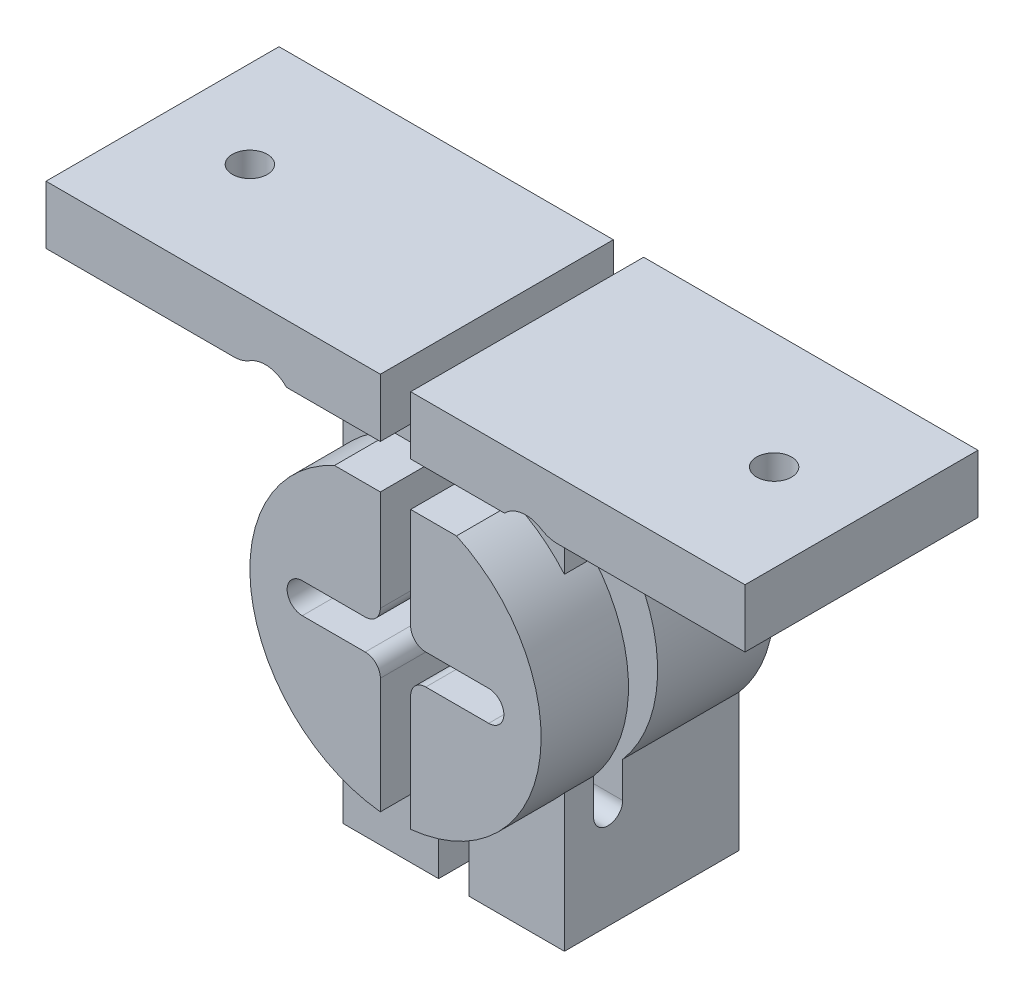
from build123d import *

# Parameters (mm, degrees)
SKETCH1_W           = 76.2
SKETCH1_H           = 50.8
BOSS_EXTRUDE1_DEPTH = 25.4
SKETCH2_W           = 76.2
SKETCH2_H           = 44.45
SKETCH2_R           = 15.875
CUT_EXTRUDE1_DEPTH  = 6.35
CUT_EXTRUDE2_DEPTH  = 12.7
CUT_EXTRUDE3_START  = -19.05
CUT_EXTRUDE3_DEPTH  = 19.05
CUT_EXTRUDE4_START  = -15.875
CUT_EXTRUDE4_DEPTH  = 31.75
CUT_EXTRUDE5_START  = -19.05
SKETCH7_R           = 3.175
CUT_EXTRUDE5_DEPTH  = 25.4
FILLET1_R           = 3.302
SKETCH8_R           = 1.905
CUT_EXTRUDE6_DEPTH  = 6.35
SKETCH9_W           = 3.302
SKETCH9_H           = 50.8
CUT_EXTRUDE7_DEPTH  = 12.7
SKETCH10_W          = 23.773678362
SKETCH10_H          = 4.7625
CUT_EXTRUDE8_DEPTH  = 6.35


with BuildPart() as part:
    # Sketch1 → Boss-Extrude1 (new body)
    with BuildSketch(Plane.XY):
        Rectangle(SKETCH1_W, SKETCH1_H)
    extrude(amount=BOSS_EXTRUDE1_DEPTH)

    # Sketch2 → Cut-Extrude1 (cut)
    with BuildSketch(Plane.XY.offset(25.4)):
        with Locations((0, -3.175)):
            Rectangle(SKETCH2_W, SKETCH2_H)
        with Locations((0, -0.127)):
            Circle(SKETCH2_R, mode=Mode.SUBTRACT)
    extrude(amount=-CUT_EXTRUDE1_DEPTH, mode=Mode.SUBTRACT)

    # Sketch3 → Cut-Extrude2 (cut)
    with BuildSketch(Plane.XY.offset(25.4)):
        with BuildLine():
            Line((10.16, -1.651), (3.302, -1.651))
            ThreePointArc((3.302, -1.651), (2.134566704, -2.134566704), (1.651, -3.302))
            Line((1.651, -3.302), (1.651, -25.4))
            Line((1.651, -25.4), (-1.651, -25.4))
            Line((-1.651, -25.4), (-1.651, -3.302))
            ThreePointArc((-1.651, -3.302), (-2.134566704, -2.134566704), (-3.302, -1.651))
            Line((-3.302, -1.651), (-10.16, -1.651))
            ThreePointArc((-10.16, -1.651), (-11.811, 0), (-10.16, 1.651))
            Line((-10.16, 1.651), (-3.302, 1.651))
            ThreePointArc((-3.302, 1.651), (-2.134566704, 2.134566704), (-1.651, 3.302))
            Line((-1.651, 3.302), (-1.651, 25.4))
            Line((-1.651, 25.4), (1.651, 25.4))
            Line((1.651, 25.4), (1.651, 3.302))
            ThreePointArc((1.651, 3.302), (2.134566704, 2.134566704), (3.302, 1.651))
            Line((3.302, 1.651), (10.16, 1.651))
            ThreePointArc((10.16, 1.651), (11.811, 0), (10.16, -1.651))
        make_face()
    extrude(amount=-CUT_EXTRUDE2_DEPTH, mode=Mode.SUBTRACT)

    # Sketch4 → Cut-Extrude3 (cut)
    with BuildSketch(Plane.XY.offset(19.05).offset(CUT_EXTRUDE3_START)):
        with BuildLine():
            Line((12.065, -25.4), (38.1, -25.4))
            Line((38.1, -25.4), (38.1, 19.05))
            Line((38.1, 19.05), (12.065, 19.05))
            Line((12.065, 19.05), (12.065, 10.190528774))
            ThreePointArc((12.065, 10.190528774), (15.875, -0.127), (12.065, -10.444528774))
            Line((12.065, -10.444528774), (12.065, -25.4))
        make_face()
        with BuildLine():
            Line((-12.065, 10.190528774), (-12.065, 19.05))
            Line((-12.065, 19.05), (-38.1, 19.05))
            Line((-38.1, 19.05), (-38.1, -25.4))
            Line((-38.1, -25.4), (-12.065, -25.4))
            Line((-12.065, -25.4), (-12.065, -10.444528774))
            ThreePointArc((-12.065, -10.444528774), (-15.875, -0.127), (-12.065, 10.190528774))
        make_face()
    extrude(amount=CUT_EXTRUDE3_DEPTH, mode=Mode.SUBTRACT)

    # Sketch6 → Cut-Extrude4 (cut)
    with BuildSketch(Plane(origin=(0, 0, 0), x_dir=(0, 0, -1), z_dir=(1, 0, 0)).offset(CUT_EXTRUDE4_START)):
        with BuildLine():
            Line((-12.7, -14.328414592), (-12.7, 14.074414592))
            ThreePointArc((-12.7, 14.074414592), (-14.2875, 15.661914592), (-15.875, 14.074414592))
            Line((-15.875, 14.074414592), (-15.875, -14.328414592))
            ThreePointArc((-15.875, -14.328414592), (-14.2875, -15.915914592), (-12.7, -14.328414592))
        make_face()
    extrude(amount=CUT_EXTRUDE4_DEPTH, mode=Mode.SUBTRACT)

    # Sketch7 → Cut-Extrude5 (cut)
    with BuildSketch(Plane.XY.offset(19.05).offset(CUT_EXTRUDE5_START)):
        with Locations((14.193918487, 16.868713665)):
            Circle(SKETCH7_R)
        with Locations((-14.193918487, 16.868713665)):
            Circle(SKETCH7_R)
    extrude(amount=CUT_EXTRUDE5_DEPTH, mode=Mode.SUBTRACT)

    # Fillet1
    fillet1_edges = [part.edges().sort_by_distance(p)[0] for p in [
        (-12.065, 14.513224103, 6.380925895),
        (-12.065, 14.513224103, 17.431574105),
        (-16.500997793, 19.05, 9.525),
        (12.065, 14.513224103, 6.380925895),
        (12.065, 14.513224103, 17.431574105),
        (16.500997793, 19.05, 9.525),
    ]]
    fillet(fillet1_edges, radius=FILLET1_R)

    # Sketch8 → Cut-Extrude6 (cut)
    with BuildSketch(Plane(origin=(0, 25.4, 0), x_dir=(1, 0, 0), z_dir=(0, 1, 0))):
        with Locations((-28.575, -12.7)):
            Circle(SKETCH8_R)
        with Locations((28.575, -12.7)):
            Circle(SKETCH8_R)
    extrude(amount=-CUT_EXTRUDE6_DEPTH, mode=Mode.SUBTRACT)

    # Sketch9 → Cut-Extrude7 (cut)
    with BuildSketch(Plane.XY.offset(12.7)):
        Rectangle(SKETCH9_W, SKETCH9_H)
    extrude(amount=-CUT_EXTRUDE7_DEPTH, mode=Mode.SUBTRACT)

    # Sketch10 → Cut-Extrude8 (cut)
    with BuildSketch(Plane.XY.offset(19.05)):
        with Locations((0, 16.66875)):
            Rectangle(SKETCH10_W, SKETCH10_H)
    extrude(amount=CUT_EXTRUDE8_DEPTH, mode=Mode.SUBTRACT)


solid = part.part
